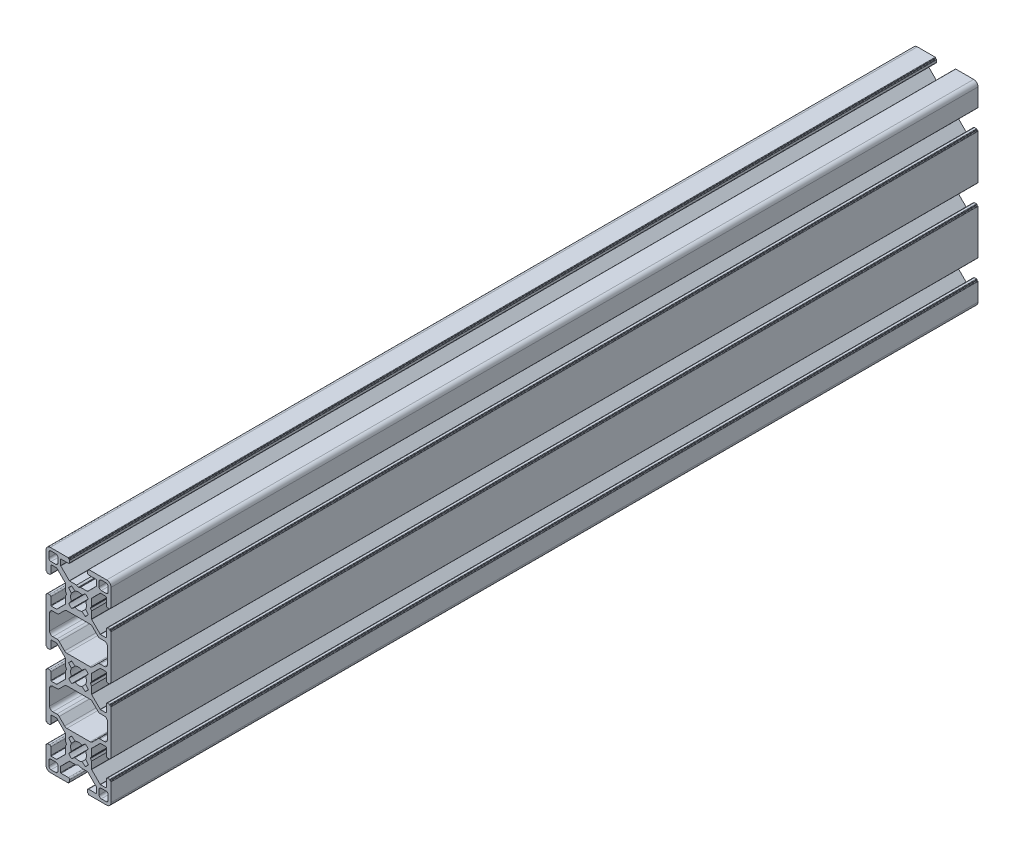
from build123d import *

# Parameters (mm, degrees)
EXTRUDE_1_DEPTH = 400


with BuildPart() as part:
    # Эскиз1 → Бобышка-Вытянуть1 (new body)
    with BuildSketch(Plane.XY):
        with BuildLine():
            Line((6.004467258, 46.508963124), (5.542586948, 45.708962771))
            ThreePointArc((5.542586948, 45.708962771), (5.501165701, 45.608963035), (5.542586948, 45.508963298))
            Line((5.542586948, 45.508963298), (6.004467258, 44.708962945))
            Line((6.004467258, 44.708962945), (6.004467258, 41.487339598))
            ThreePointArc((6.004467258, 41.487339598), (6.019691347, 41.410802923), (6.063045884, 41.345918259))
            Line((6.063045884, 41.345918259), (9.991421447, 37.417541696))
            ThreePointArc((9.991421447, 37.417541696), (10.056306123, 37.374187133), (10.132842821, 37.358963035))
            Line((10.132842821, 37.358963035), (12.600000821, 37.358963035))
            ThreePointArc((12.600000821, 37.358963035), (12.741422177, 37.417541678), (12.800000821, 37.558963035))
            Line((12.800000821, 37.558963035), (12.800000821, 40.958963035))
            ThreePointArc((12.800000821, 40.958963035), (12.975736752, 41.383227103), (13.400000821, 41.558963035))
            Line((13.400000821, 41.558963035), (14.300000334, 41.558963035))
            ThreePointArc((14.300000334, 41.558963035), (14.44142169, 41.500384391), (14.500000334, 41.358963035))
            Line((14.500000334, 41.358963035), (14.500000334, 41.258963035))
            ThreePointArc((14.500000334, 41.258963035), (14.558578978, 41.117541678), (14.700000334, 41.058963035))
            Line((14.700000334, 41.058963035), (14.8, 41.058963035))
            ThreePointArc((14.8, 41.058963035), (14.941421356, 41.000384391), (15, 40.858963035))
            Line((15, 40.858963035), (15, 20.358963035))
            ThreePointArc((15, 20.358963035), (14.941421356, 20.217541678), (14.8, 20.158963035))
            Line((14.8, 20.158963035), (14.700000334, 20.158963035))
            ThreePointArc((14.700000334, 20.158963035), (14.558578978, 20.100384391), (14.500000334, 19.958963035))
            Line((14.500000334, 19.958963035), (14.500000334, 19.858963035))
            ThreePointArc((14.500000334, 19.858963035), (14.44142169, 19.717541678), (14.300000334, 19.658963035))
            Line((14.300000334, 19.658963035), (13.400000821, 19.658963035))
            ThreePointArc((13.400000821, 19.658963035), (12.975736752, 19.834698966), (12.800000821, 20.258963035))
            Line((12.800000821, 20.258963035), (12.800000821, 23.658963035))
            ThreePointArc((12.800000821, 23.658963035), (12.741422177, 23.800384391), (12.600000821, 23.858963035))
            Line((12.600000821, 23.858963035), (10.132842821, 23.858963035))
            ThreePointArc((10.132842821, 23.858963035), (10.056306123, 23.843738936), (9.991421447, 23.800384373))
            Line((9.991421447, 23.800384373), (6.063045884, 19.87200781))
            ThreePointArc((6.063045884, 19.87200781), (6.019691347, 19.807123146), (6.004467258, 19.730586472))
            Line((6.004467258, 19.730586472), (6.004467258, 16.508963124))
            Line((6.004467258, 16.508963124), (5.542586948, 15.708962771))
            ThreePointArc((5.542586948, 15.708962771), (5.515792105, 15.608963035), (5.542586948, 15.508963298))
            Line((5.542586948, 15.508963298), (6.004467258, 14.708962945))
            Line((6.004467258, 14.708962945), (6.004467258, 11.487339598))
            ThreePointArc((6.004467258, 11.487339598), (6.019691347, 11.410802923), (6.063045884, 11.345918259))
            Line((6.063045884, 11.345918259), (9.991421447, 7.417541696))
            ThreePointArc((9.991421447, 7.417541696), (10.056306123, 7.374187133), (10.132842821, 7.358963035))
            Line((10.132842821, 7.358963035), (12.600000821, 7.358963035))
            ThreePointArc((12.600000821, 7.358963035), (12.741422177, 7.417541678), (12.800000821, 7.558963035))
            Line((12.800000821, 7.558963035), (12.800000821, 10.958963035))
            ThreePointArc((12.800000821, 10.958963035), (12.975736752, 11.383227103), (13.400000821, 11.558963035))
            Line((13.400000821, 11.558963035), (14.300000334, 11.558963035))
            ThreePointArc((14.300000334, 11.558963035), (14.44142169, 11.500384391), (14.500000334, 11.358963035))
            Line((14.500000334, 11.358963035), (14.500000334, 11.258962909))
            ThreePointArc((14.500000334, 11.258962909), (14.558578978, 11.117541553), (14.700000334, 11.058962909))
            Line((14.700000334, 11.058962909), (14.8, 11.058962909))
            ThreePointArc((14.8, 11.058962909), (14.941421356, 11.000384266), (15, 10.858962909))
            Line((15, 10.858962909), (15, 2.608963035))
            ThreePointArc((15, 2.608963035), (14.414213562, 1.194749472), (13, 0.608963035))
            Line((13, 0.608963035), (4.75, 0.608963035))
            ThreePointArc((4.75, 0.608963035), (4.608578644, 0.667541678), (4.55, 0.808963035))
            Line((4.55, 0.808963035), (4.55, 0.908963035))
            ThreePointArc((4.55, 0.908963035), (4.491421356, 1.050384391), (4.35, 1.108963035))
            Line((4.35, 1.108963035), (4.25, 1.108963035))
            ThreePointArc((4.25, 1.108963035), (4.108578644, 1.167541678), (4.05, 1.308963035))
            Line((4.05, 1.308963035), (4.05, 2.208963035))
            ThreePointArc((4.05, 2.208963035), (4.225735931, 2.633227103), (4.65, 2.808963035))
            Line((4.65, 2.808963035), (8.05, 2.808963035))
            ThreePointArc((8.05, 2.808963035), (8.191421356, 2.867541678), (8.25, 3.008963035))
            Line((8.25, 3.008963035), (8.25, 5.476120035))
            ThreePointArc((8.25, 5.476120035), (8.234775894, 5.552656772), (8.191421308, 5.617541481))
            Line((8.191421308, 5.617541481), (4.258577305, 9.550384483))
            ThreePointArc((4.258577305, 9.550384483), (4.193692724, 9.593738965), (4.117156145, 9.608963035))
            Line((4.117156145, 9.608963035), (0.899999648, 9.608963035))
            Line((0.899999648, 9.608963035), (0.101934004, 10.069726315))
            ThreePointArc((0.101934004, 10.069726315), (0, 10.097039442), (-0.101934004, 10.069726315))
            Line((-0.101934004, 10.069726315), (-0.899999648, 9.608963035))
            Line((-0.899999648, 9.608963035), (-4.117156145, 9.608963035))
            ThreePointArc((-4.117156145, 9.608963035), (-4.193692724, 9.593738965), (-4.258577305, 9.550384483))
            Line((-4.258577305, 9.550384483), (-8.191421308, 5.617541481))
            ThreePointArc((-8.191421308, 5.617541481), (-8.234775894, 5.552656772), (-8.25, 5.476120035))
            Line((-8.25, 5.476120035), (-8.25, 3.008963035))
            ThreePointArc((-8.25, 3.008963035), (-8.191421356, 2.867541678), (-8.05, 2.808963035))
            Line((-8.05, 2.808963035), (-4.65, 2.808963035))
            ThreePointArc((-4.65, 2.808963035), (-4.225735931, 2.633227103), (-4.05, 2.208963035))
            Line((-4.05, 2.208963035), (-4.05, 1.308963035))
            ThreePointArc((-4.05, 1.308963035), (-4.108578644, 1.167541678), (-4.25, 1.108963035))
            Line((-4.25, 1.108963035), (-4.35, 1.108963035))
            ThreePointArc((-4.35, 1.108963035), (-4.491421356, 1.050384391), (-4.55, 0.908963035))
            Line((-4.55, 0.908963035), (-4.55, 0.808963035))
            ThreePointArc((-4.55, 0.808963035), (-4.608578644, 0.667541678), (-4.75, 0.608963035))
            Line((-4.75, 0.608963035), (-13, 0.608963035))
            ThreePointArc((-13, 0.608963035), (-14.414213562, 1.194749472), (-15, 2.608963035))
            Line((-15, 2.608963035), (-15, 10.858962909))
            ThreePointArc((-15, 10.858962909), (-14.941421356, 11.000384266), (-14.8, 11.058962909))
            Line((-14.8, 11.058962909), (-14.700000334, 11.058962909))
            ThreePointArc((-14.700000334, 11.058962909), (-14.558578978, 11.117541553), (-14.500000334, 11.258962909))
            Line((-14.500000334, 11.258962909), (-14.500000334, 11.358963035))
            ThreePointArc((-14.500000334, 11.358963035), (-14.44142169, 11.500384391), (-14.300000334, 11.558963035))
            Line((-14.300000334, 11.558963035), (-13.400000821, 11.558963035))
            ThreePointArc((-13.400000821, 11.558963035), (-12.975736752, 11.383227103), (-12.800000821, 10.958963035))
            Line((-12.800000821, 10.958963035), (-12.800000821, 7.558963035))
            ThreePointArc((-12.800000821, 7.558963035), (-12.741422177, 7.417541678), (-12.600000821, 7.358963035))
            Line((-12.600000821, 7.358963035), (-10.132842821, 7.358963035))
            ThreePointArc((-10.132842821, 7.358963035), (-10.056306123, 7.374187133), (-9.991421447, 7.417541696))
            Line((-9.991421447, 7.417541696), (-6.063045884, 11.345918259))
            ThreePointArc((-6.063045884, 11.345918259), (-6.019691347, 11.410802923), (-6.004467258, 11.487339598))
            Line((-6.004467258, 11.487339598), (-6.004467258, 14.708962945))
            Line((-6.004467258, 14.708962945), (-5.542586948, 15.508963298))
            ThreePointArc((-5.542586948, 15.508963298), (-5.515792105, 15.608963035), (-5.542586948, 15.708962771))
            Line((-5.542586948, 15.708962771), (-6.004467258, 16.508963124))
            Line((-6.004467258, 16.508963124), (-6.004467258, 19.730586472))
            ThreePointArc((-6.004467258, 19.730586472), (-6.019691347, 19.807123146), (-6.063045884, 19.87200781))
            Line((-6.063045884, 19.87200781), (-9.991421447, 23.800384373))
            ThreePointArc((-9.991421447, 23.800384373), (-10.056306123, 23.843738936), (-10.132842821, 23.858963035))
            Line((-10.132842821, 23.858963035), (-12.600000821, 23.858963035))
            ThreePointArc((-12.600000821, 23.858963035), (-12.741422177, 23.800384391), (-12.800000821, 23.658963035))
            Line((-12.800000821, 23.658963035), (-12.800000821, 20.258963035))
            ThreePointArc((-12.800000821, 20.258963035), (-12.975736752, 19.834698966), (-13.400000821, 19.658963035))
            Line((-13.400000821, 19.658963035), (-14.300000334, 19.658963035))
            ThreePointArc((-14.300000334, 19.658963035), (-14.44142169, 19.717541678), (-14.500000334, 19.858963035))
            Line((-14.500000334, 19.858963035), (-14.500000334, 19.958963035))
            ThreePointArc((-14.500000334, 19.958963035), (-14.558578978, 20.100384391), (-14.700000334, 20.158963035))
            Line((-14.700000334, 20.158963035), (-14.8, 20.158963035))
            ThreePointArc((-14.8, 20.158963035), (-14.941421356, 20.217541678), (-15, 20.358963035))
            Line((-15, 20.358963035), (-15, 40.858963035))
            ThreePointArc((-15, 40.858963035), (-14.941421356, 41.000384391), (-14.8, 41.058963035))
            Line((-14.8, 41.058963035), (-14.700000334, 41.058963035))
            ThreePointArc((-14.700000334, 41.058963035), (-14.558578978, 41.117541678), (-14.500000334, 41.258963035))
            Line((-14.500000334, 41.258963035), (-14.500000334, 41.358963035))
            ThreePointArc((-14.500000334, 41.358963035), (-14.44142169, 41.500384391), (-14.300000334, 41.558963035))
            Line((-14.300000334, 41.558963035), (-13.400000821, 41.558963035))
            ThreePointArc((-13.400000821, 41.558963035), (-12.975736752, 41.383227103), (-12.800000821, 40.958963035))
            Line((-12.800000821, 40.958963035), (-12.800000821, 37.558963035))
            ThreePointArc((-12.800000821, 37.558963035), (-12.741422177, 37.417541678), (-12.600000821, 37.358963035))
            Line((-12.600000821, 37.358963035), (-10.132842821, 37.358963035))
            ThreePointArc((-10.132842821, 37.358963035), (-10.056306123, 37.374187133), (-9.991421447, 37.417541696))
            Line((-9.991421447, 37.417541696), (-6.063045884, 41.345918259))
            ThreePointArc((-6.063045884, 41.345918259), (-6.019691347, 41.410802923), (-6.004467258, 41.487339598))
            Line((-6.004467258, 41.487339598), (-6.004467258, 44.708962945))
            Line((-6.004467258, 44.708962945), (-5.542586948, 45.508963298))
            ThreePointArc((-5.542586948, 45.508963298), (-5.501165701, 45.608963035), (-5.542586948, 45.708962771))
            Line((-5.542586948, 45.708962771), (-6.004467258, 46.508963124))
            Line((-6.004467258, 46.508963124), (-6.004467258, 49.730586472))
            ThreePointArc((-6.004467258, 49.730586472), (-6.004467253, 49.813429171), (-6.063045884, 49.87200781))
            Line((-6.063045884, 49.87200781), (-9.991421447, 53.800384373))
            ThreePointArc((-9.991421447, 53.800384373), (-10.056306123, 53.843738936), (-10.132842821, 53.858963035))
            Line((-10.132842821, 53.858963035), (-12.600000821, 53.858963035))
            ThreePointArc((-12.600000821, 53.858963035), (-12.741422177, 53.800384391), (-12.800000821, 53.658963035))
            Line((-12.800000821, 53.658963035), (-12.800000821, 50.258963035))
            ThreePointArc((-12.800000821, 50.258963035), (-12.975736752, 49.834698966), (-13.400000821, 49.658963035))
            Line((-13.400000821, 49.658963035), (-14.300000334, 49.658963035))
            ThreePointArc((-14.300000334, 49.658963035), (-14.44142169, 49.717541678), (-14.500000334, 49.858963035))
            Line((-14.500000334, 49.858963035), (-14.500000334, 49.958963035))
            ThreePointArc((-14.500000334, 49.958963035), (-14.558578978, 50.100384391), (-14.700000334, 50.158963035))
            Line((-14.700000334, 50.158963035), (-14.8, 50.158963035))
            ThreePointArc((-14.8, 50.158963035), (-14.941421356, 50.217541678), (-15, 50.358963035))
            Line((-15, 50.358963035), (-15, 70.858963035))
            ThreePointArc((-15, 70.858963035), (-14.941421356, 71.000384391), (-14.8, 71.058963035))
            Line((-14.8, 71.058963035), (-14.700000334, 71.058963035))
            ThreePointArc((-14.700000334, 71.058963035), (-14.558578978, 71.117541678), (-14.500000334, 71.258963035))
            Line((-14.500000334, 71.258963035), (-14.500000334, 71.358963035))
            ThreePointArc((-14.500000334, 71.358963035), (-14.44142169, 71.500384391), (-14.300000334, 71.558963035))
            Line((-14.300000334, 71.558963035), (-13.400000821, 71.558963035))
            ThreePointArc((-13.400000821, 71.558963035), (-12.975736752, 71.383227103), (-12.800000821, 70.958963035))
            Line((-12.800000821, 70.958963035), (-12.800000821, 67.558963035))
            ThreePointArc((-12.800000821, 67.558963035), (-12.741422177, 67.417541678), (-12.600000821, 67.358963035))
            Line((-12.600000821, 67.358963035), (-10.132842821, 67.358963035))
            ThreePointArc((-10.132842821, 67.358963035), (-10.056306123, 67.374187133), (-9.991421447, 67.417541696))
            Line((-9.991421447, 67.417541696), (-6.063045884, 71.345918259))
            ThreePointArc((-6.063045884, 71.345918259), (-6.019691347, 71.410802923), (-6.004467258, 71.487339598))
            Line((-6.004467258, 71.487339598), (-6.004467258, 74.708962945))
            Line((-6.004467258, 74.708962945), (-5.542586948, 75.508963298))
            ThreePointArc((-5.542586948, 75.508963298), (-5.515792105, 75.608963035), (-5.542586948, 75.708962771))
            Line((-5.542586948, 75.708962771), (-6.004467258, 76.508963124))
            Line((-6.004467258, 76.508963124), (-6.004467258, 79.730586472))
            ThreePointArc((-6.004467258, 79.730586472), (-6.019691347, 79.807123146), (-6.063045884, 79.87200781))
            Line((-6.063045884, 79.87200781), (-9.991421447, 83.800384373))
            ThreePointArc((-9.991421447, 83.800384373), (-10.056306123, 83.843738936), (-10.132842821, 83.858963035))
            Line((-10.132842821, 83.858963035), (-12.600000821, 83.858963035))
            ThreePointArc((-12.600000821, 83.858963035), (-12.741422177, 83.800384391), (-12.800000821, 83.658963035))
            Line((-12.800000821, 83.658963035), (-12.800000821, 80.258963035))
            ThreePointArc((-12.800000821, 80.258963035), (-12.975736752, 79.834698966), (-13.400000821, 79.658963035))
            Line((-13.400000821, 79.658963035), (-14.300000334, 79.658963035))
            ThreePointArc((-14.300000334, 79.658963035), (-14.44142169, 79.717541678), (-14.500000334, 79.858963035))
            Line((-14.500000334, 79.858963035), (-14.500000334, 79.95896316))
            ThreePointArc((-14.500000334, 79.95896316), (-14.558578978, 80.100384516), (-14.700000334, 80.15896316))
            Line((-14.700000334, 80.15896316), (-14.8, 80.15896316))
            ThreePointArc((-14.8, 80.15896316), (-14.941421356, 80.217541804), (-15, 80.35896316))
            Line((-15, 80.35896316), (-15, 88.608963035))
            ThreePointArc((-15, 88.608963035), (-14.414213562, 90.023176597), (-13, 90.608963035))
            Line((-13, 90.608963035), (-4.75, 90.608963035))
            ThreePointArc((-4.75, 90.608963035), (-4.608578644, 90.550384391), (-4.55, 90.408963035))
            Line((-4.55, 90.408963035), (-4.55, 90.308963035))
            ThreePointArc((-4.55, 90.308963035), (-4.491421356, 90.167541678), (-4.35, 90.108963035))
            Line((-4.35, 90.108963035), (-4.25, 90.108963035))
            ThreePointArc((-4.25, 90.108963035), (-4.108578644, 90.050384391), (-4.05, 89.908963035))
            Line((-4.05, 89.908963035), (-4.05, 89.008963035))
            ThreePointArc((-4.05, 89.008963035), (-4.225735931, 88.584698966), (-4.65, 88.408963035))
            Line((-4.65, 88.408963035), (-8.05, 88.408963035))
            ThreePointArc((-8.05, 88.408963035), (-8.191421356, 88.350384391), (-8.25, 88.208963035))
            Line((-8.25, 88.208963035), (-8.25, 85.741806035))
            ThreePointArc((-8.25, 85.741806035), (-8.234775894, 85.665269298), (-8.191421308, 85.600384589))
            Line((-8.191421308, 85.600384589), (-4.258577305, 81.667541587))
            ThreePointArc((-4.258577305, 81.667541587), (-4.193692724, 81.624187104), (-4.117156145, 81.608963035))
            Line((-4.117156145, 81.608963035), (-0.899999648, 81.608963035))
            Line((-0.899999648, 81.608963035), (-0.101934004, 81.148199754))
            ThreePointArc((-0.101934004, 81.148199754), (0, 81.120886627), (0.101934004, 81.148199754))
            Line((0.101934004, 81.148199754), (0.899999648, 81.608963035))
            Line((0.899999648, 81.608963035), (4.117156145, 81.608963035))
            ThreePointArc((4.117156145, 81.608963035), (4.193692724, 81.624187104), (4.258577305, 81.667541587))
            Line((4.258577305, 81.667541587), (8.191421308, 85.600384589))
            ThreePointArc((8.191421308, 85.600384589), (8.234775894, 85.665269298), (8.25, 85.741806035))
            Line((8.25, 85.741806035), (8.25, 88.208963035))
            ThreePointArc((8.25, 88.208963035), (8.191421356, 88.350384391), (8.05, 88.408963035))
            Line((8.05, 88.408963035), (4.65, 88.408963035))
            ThreePointArc((4.65, 88.408963035), (4.225735931, 88.584698966), (4.05, 89.008963035))
            Line((4.05, 89.008963035), (4.05, 89.908963035))
            ThreePointArc((4.05, 89.908963035), (4.108578644, 90.050384391), (4.25, 90.108963035))
            Line((4.25, 90.108963035), (4.35, 90.108963035))
            ThreePointArc((4.35, 90.108963035), (4.491421356, 90.167541678), (4.55, 90.308963035))
            Line((4.55, 90.308963035), (4.55, 90.408963035))
            ThreePointArc((4.55, 90.408963035), (4.608578644, 90.550384391), (4.75, 90.608963035))
            Line((4.75, 90.608963035), (13, 90.608963035))
            ThreePointArc((13, 90.608963035), (14.414213562, 90.023176597), (15, 88.608963035))
            Line((15, 88.608963035), (15, 80.35896316))
            ThreePointArc((15, 80.35896316), (14.941421356, 80.217541804), (14.8, 80.15896316))
            Line((14.8, 80.15896316), (14.700000334, 80.15896316))
            ThreePointArc((14.700000334, 80.15896316), (14.558578978, 80.100384516), (14.500000334, 79.95896316))
            Line((14.500000334, 79.95896316), (14.500000334, 79.858963035))
            ThreePointArc((14.500000334, 79.858963035), (14.44142169, 79.717541678), (14.300000334, 79.658963035))
            Line((14.300000334, 79.658963035), (13.400000821, 79.658963035))
            ThreePointArc((13.400000821, 79.658963035), (12.975736752, 79.834698966), (12.800000821, 80.258963035))
            Line((12.800000821, 80.258963035), (12.800000821, 83.658963035))
            ThreePointArc((12.800000821, 83.658963035), (12.741422177, 83.800384391), (12.600000821, 83.858963035))
            Line((12.600000821, 83.858963035), (10.132842821, 83.858963035))
            ThreePointArc((10.132842821, 83.858963035), (10.056306123, 83.843738936), (9.991421447, 83.800384373))
            Line((9.991421447, 83.800384373), (6.063045884, 79.87200781))
            ThreePointArc((6.063045884, 79.87200781), (6.019691347, 79.807123146), (6.004467258, 79.730586472))
            Line((6.004467258, 79.730586472), (6.004467258, 76.508963124))
            Line((6.004467258, 76.508963124), (5.542586948, 75.708962771))
            ThreePointArc((5.542586948, 75.708962771), (5.515792105, 75.608963035), (5.542586948, 75.508963298))
            Line((5.542586948, 75.508963298), (6.004467258, 74.708962945))
            Line((6.004467258, 74.708962945), (6.004467258, 71.487339598))
            ThreePointArc((6.004467258, 71.487339598), (6.019691347, 71.410802923), (6.063045884, 71.345918259))
            Line((6.063045884, 71.345918259), (9.991421447, 67.417541696))
            ThreePointArc((9.991421447, 67.417541696), (10.056306123, 67.374187133), (10.132842821, 67.358963035))
            Line((10.132842821, 67.358963035), (12.600000821, 67.358963035))
            ThreePointArc((12.600000821, 67.358963035), (12.741422177, 67.417541678), (12.800000821, 67.558963035))
            Line((12.800000821, 67.558963035), (12.800000821, 70.958963035))
            ThreePointArc((12.800000821, 70.958963035), (12.975736752, 71.383227103), (13.400000821, 71.558963035))
            Line((13.400000821, 71.558963035), (14.300000334, 71.558963035))
            ThreePointArc((14.300000334, 71.558963035), (14.44142169, 71.500384391), (14.500000334, 71.358963035))
            Line((14.500000334, 71.358963035), (14.500000334, 71.258963035))
            ThreePointArc((14.500000334, 71.258963035), (14.558578978, 71.117541678), (14.700000334, 71.058963035))
            Line((14.700000334, 71.058963035), (14.8, 71.058963035))
            ThreePointArc((14.8, 71.058963035), (14.941421356, 71.000384391), (15, 70.858963035))
            Line((15, 70.858963035), (15, 50.358963035))
            ThreePointArc((15, 50.358963035), (14.941421356, 50.217541678), (14.8, 50.158963035))
            Line((14.8, 50.158963035), (14.700000334, 50.158963035))
            ThreePointArc((14.700000334, 50.158963035), (14.558578978, 50.100384391), (14.500000334, 49.958963035))
            Line((14.500000334, 49.958963035), (14.500000334, 49.858963035))
            ThreePointArc((14.500000334, 49.858963035), (14.44142169, 49.717541678), (14.300000334, 49.658963035))
            Line((14.300000334, 49.658963035), (13.400000821, 49.658963035))
            ThreePointArc((13.400000821, 49.658963035), (12.975736752, 49.834698966), (12.800000821, 50.258963035))
            Line((12.800000821, 50.258963035), (12.800000821, 53.658963035))
            ThreePointArc((12.800000821, 53.658963035), (12.741422177, 53.800384391), (12.600000821, 53.858963035))
            Line((12.600000821, 53.858963035), (10.132842821, 53.858963035))
            ThreePointArc((10.132842821, 53.858963035), (10.056306123, 53.843738936), (9.991421447, 53.800384373))
            Line((9.991421447, 53.800384373), (6.063045884, 49.87200781))
            ThreePointArc((6.063045884, 49.87200781), (6.019691347, 49.807123146), (6.004467258, 49.730586472))
            Line((6.004467258, 49.730586472), (6.004467258, 46.508963124))
        make_face()
        with BuildLine():
            Line((1.600130621, 12.328401803), (3.154670945, 11.103627173))
            ThreePointArc((3.154670945, 11.103627173), (3.897156783, 11.727962003), (4.518401855, 12.473034994))
            Line((4.518401855, 12.473034994), (3.28056155, 14.008833067))
            ThreePointArc((3.28056155, 14.008833067), (3.65, 15.608963035), (3.28056155, 17.209093003))
            Line((3.28056155, 17.209093003), (4.518401855, 18.744891075))
            ThreePointArc((4.518401855, 18.744891075), (3.897156783, 19.489964066), (3.154670945, 20.114298897))
            Line((3.154670945, 20.114298897), (1.600130621, 18.889524267))
            ThreePointArc((1.600130621, 18.889524267), (0, 19.258963035), (-1.600130621, 18.889524267))
            Line((-1.600130621, 18.889524267), (-3.154670945, 20.114298897))
            ThreePointArc((-3.154670945, 20.114298897), (-3.897156783, 19.489964066), (-4.518401855, 18.744891075))
            Line((-4.518401855, 18.744891075), (-3.28056155, 17.209093003))
            ThreePointArc((-3.28056155, 17.209093003), (-3.65, 15.608963035), (-3.28056155, 14.008833067))
            Line((-3.28056155, 14.008833067), (-4.518401855, 12.473034994))
            ThreePointArc((-4.518401855, 12.473034994), (-3.897156783, 11.727962003), (-3.154670945, 11.103627173))
            Line((-3.154670945, 11.103627173), (-1.600130621, 12.328401803))
            ThreePointArc((-1.600130621, 12.328401803), (0, 11.958963035), (1.600130621, 12.328401803))
        make_face(mode=Mode.SUBTRACT)
        with BuildLine():
            Line((10.500000904, 6.108962861), (12.700000904, 6.108962861))
            ThreePointArc((12.700000904, 6.108962861), (13.407107685, 5.816069642), (13.700000904, 5.108962861))
            Line((13.700000904, 5.108962861), (13.700000904, 2.908962861))
            ThreePointArc((13.700000904, 2.908962861), (13.407107685, 2.20185608), (12.700000904, 1.908962861))
            Line((12.700000904, 1.908962861), (10.500000904, 1.908962861))
            ThreePointArc((10.500000904, 1.908962861), (9.792894123, 2.20185608), (9.500000904, 2.908962861))
            Line((9.500000904, 2.908962861), (9.500000904, 5.108962861))
            ThreePointArc((9.500000904, 5.108962861), (9.792894123, 5.816069642), (10.500000904, 6.108962861))
        make_face(mode=Mode.SUBTRACT)
        with BuildLine():
            Line((8.927207818, 25.069623242), (6.410354062, 22.552769143))
            ThreePointArc((6.410354062, 22.552769143), (5.923719026, 22.227609968), (5.349693844, 22.113429242))
            Line((5.349693844, 22.113429242), (-5.349693844, 22.113429242))
            ThreePointArc((-5.349693844, 22.113429242), (-5.923719026, 22.227609968), (-6.410354062, 22.552769143))
            Line((-6.410354062, 22.552769143), (-8.927207746, 25.06962317))
            ThreePointArc((-8.927207746, 25.06962317), (-9.413842755, 25.394782323), (-9.987867904, 25.508963035))
            Line((-9.987867904, 25.508963035), (-11.849999904, 25.508963035))
            ThreePointArc((-11.849999904, 25.508963035), (-12.910660076, 25.948302863), (-13.349999904, 27.008963035))
            Line((-13.349999904, 27.008963035), (-13.349999904, 34.208963035))
            ThreePointArc((-13.349999904, 34.208963035), (-12.910660076, 35.269623206), (-11.849999904, 35.708963035))
            Line((-11.849999904, 35.708963035), (-9.987867904, 35.708963035))
            ThreePointArc((-9.987867904, 35.708963035), (-9.413842802, 35.823143727), (-8.927207818, 36.148302827))
            Line((-8.927207818, 36.148302827), (-6.410354008, 38.665156981))
            ThreePointArc((-6.410354008, 38.665156981), (-5.923718979, 38.990316121), (-5.349693818, 39.104496827))
            Line((-5.349693818, 39.104496827), (5.349693818, 39.104496827))
            ThreePointArc((5.349693818, 39.104496827), (5.923718979, 38.990316121), (6.410354008, 38.665156981))
            Line((6.410354008, 38.665156981), (8.927207818, 36.148302827))
            ThreePointArc((8.927207818, 36.148302827), (9.413842802, 35.823143727), (9.987867904, 35.708963035))
            Line((9.987867904, 35.708963035), (11.849999904, 35.708963035))
            ThreePointArc((11.849999904, 35.708963035), (12.910660076, 35.269623206), (13.349999904, 34.208963035))
            Line((13.349999904, 34.208963035), (13.349999904, 27.008963035))
            ThreePointArc((13.349999904, 27.008963035), (12.910660076, 25.948302863), (11.849999904, 25.508963035))
            Line((11.849999904, 25.508963035), (9.987867904, 25.508963035))
            ThreePointArc((9.987867904, 25.508963035), (9.413842802, 25.394782343), (8.927207818, 25.069623242))
        make_face(mode=Mode.SUBTRACT)
        with BuildLine():
            Line((-1.600130621, 42.328401803), (-3.154670945, 41.103627173))
            ThreePointArc((-3.154670945, 41.103627173), (-3.897156783, 41.727962003), (-4.518401855, 42.473034994))
            Line((-4.518401855, 42.473034994), (-3.28056155, 44.008833067))
            ThreePointArc((-3.28056155, 44.008833067), (-3.65, 45.608963035), (-3.28056155, 47.209093003))
            Line((-3.28056155, 47.209093003), (-4.518401855, 48.744891075))
            ThreePointArc((-4.518401855, 48.744891075), (-3.897156783, 49.489964066), (-3.154670945, 50.114298897))
            Line((-3.154670945, 50.114298897), (-1.600130621, 48.889524267))
            ThreePointArc((-1.600130621, 48.889524267), (0, 49.258963035), (1.600130621, 48.889524267))
            Line((1.600130621, 48.889524267), (3.154670945, 50.114298897))
            ThreePointArc((3.154670945, 50.114298897), (3.897156783, 49.489964066), (4.518401855, 48.744891075))
            Line((4.518401855, 48.744891075), (3.28056155, 47.209093003))
            ThreePointArc((3.28056155, 47.209093003), (3.65, 45.608963035), (3.28056155, 44.008833067))
            Line((3.28056155, 44.008833067), (4.518401855, 42.473034994))
            ThreePointArc((4.518401855, 42.473034994), (3.897156783, 41.727962003), (3.154670945, 41.103627173))
            Line((3.154670945, 41.103627173), (1.600130621, 42.328401803))
            ThreePointArc((1.600130621, 42.328401803), (0, 41.958963035), (-1.600130621, 42.328401803))
        make_face(mode=Mode.SUBTRACT)
        with BuildLine():
            Line((-9.500000904, 2.908962861), (-9.500000904, 5.108962861))
            ThreePointArc((-9.500000904, 5.108962861), (-9.792894123, 5.816069642), (-10.500000904, 6.108962861))
            Line((-10.500000904, 6.108962861), (-12.700000904, 6.108962861))
            ThreePointArc((-12.700000904, 6.108962861), (-13.407107685, 5.816069642), (-13.700000904, 5.108962861))
            Line((-13.700000904, 5.108962861), (-13.700000904, 2.908962861))
            ThreePointArc((-13.700000904, 2.908962861), (-13.407107685, 2.20185608), (-12.700000904, 1.908962861))
            Line((-12.700000904, 1.908962861), (-10.500000904, 1.908962861))
            ThreePointArc((-10.500000904, 1.908962861), (-9.792894123, 2.20185608), (-9.500000904, 2.908962861))
        make_face(mode=Mode.SUBTRACT)
        with BuildLine():
            Line((-5.349693818, 52.113429242), (5.349693818, 52.113429242))
            ThreePointArc((5.349693818, 52.113429242), (5.923718979, 52.227609948), (6.410354008, 52.552769089))
            Line((6.410354008, 52.552769089), (8.927207818, 55.069623242))
            ThreePointArc((8.927207818, 55.069623242), (9.413842802, 55.394782343), (9.987867904, 55.508963035))
            Line((9.987867904, 55.508963035), (11.849999904, 55.508963035))
            ThreePointArc((11.849999904, 55.508963035), (12.910660076, 55.948302863), (13.349999904, 57.008963035))
            Line((13.349999904, 57.008963035), (13.349999904, 64.208963035))
            ThreePointArc((13.349999904, 64.208963035), (12.910660076, 65.269623206), (11.849999904, 65.708963035))
            Line((11.849999904, 65.708963035), (9.987867904, 65.708963035))
            ThreePointArc((9.987867904, 65.708963035), (9.413842802, 65.823143727), (8.927207818, 66.148302827))
            Line((8.927207818, 66.148302827), (6.410354062, 68.665156927))
            ThreePointArc((6.410354062, 68.665156927), (5.923719026, 68.990316102), (5.349693844, 69.104496827))
            Line((5.349693844, 69.104496827), (-5.349693844, 69.104496827))
            ThreePointArc((-5.349693844, 69.104496827), (-5.923719026, 68.990316102), (-6.410354062, 68.665156927))
            Line((-6.410354062, 68.665156927), (-8.927207746, 66.1483029))
            ThreePointArc((-8.927207746, 66.1483029), (-9.413842755, 65.823143746), (-9.987867904, 65.708963035))
            Line((-9.987867904, 65.708963035), (-11.849999904, 65.708963035))
            ThreePointArc((-11.849999904, 65.708963035), (-12.910660076, 65.269623206), (-13.349999904, 64.208963035))
            Line((-13.349999904, 64.208963035), (-13.349999904, 57.008963035))
            ThreePointArc((-13.349999904, 57.008963035), (-12.910660076, 55.948302863), (-11.849999904, 55.508963035))
            Line((-11.849999904, 55.508963035), (-9.987867904, 55.508963035))
            ThreePointArc((-9.987867904, 55.508963035), (-9.413842802, 55.394782343), (-8.927207818, 55.069623242))
            Line((-8.927207818, 55.069623242), (-6.410354008, 52.552769089))
            ThreePointArc((-6.410354008, 52.552769089), (-5.923718979, 52.227609948), (-5.349693818, 52.113429242))
        make_face(mode=Mode.SUBTRACT)
        with BuildLine():
            Line((-1.600130621, 78.889524267), (-3.154670945, 80.114298897))
            ThreePointArc((-3.154670945, 80.114298897), (-3.897156783, 79.489964066), (-4.518401855, 78.744891075))
            Line((-4.518401855, 78.744891075), (-3.28056155, 77.209093003))
            ThreePointArc((-3.28056155, 77.209093003), (-3.65, 75.608963035), (-3.28056155, 74.008833067))
            Line((-3.28056155, 74.008833067), (-4.518401855, 72.473034994))
            ThreePointArc((-4.518401855, 72.473034994), (-3.897156783, 71.727962003), (-3.154670945, 71.103627173))
            Line((-3.154670945, 71.103627173), (-1.600130621, 72.328401803))
            ThreePointArc((-1.600130621, 72.328401803), (0, 71.958963035), (1.600130621, 72.328401803))
            Line((1.600130621, 72.328401803), (3.154670945, 71.103627173))
            ThreePointArc((3.154670945, 71.103627173), (3.897156783, 71.727962003), (4.518401855, 72.473034994))
            Line((4.518401855, 72.473034994), (3.28056155, 74.008833067))
            ThreePointArc((3.28056155, 74.008833067), (3.65, 75.608963035), (3.28056155, 77.209093003))
            Line((3.28056155, 77.209093003), (4.518401855, 78.744891075))
            ThreePointArc((4.518401855, 78.744891075), (3.897156783, 79.489964066), (3.154670945, 80.114298897))
            Line((3.154670945, 80.114298897), (1.600130621, 78.889524267))
            ThreePointArc((1.600130621, 78.889524267), (0, 79.258963035), (-1.600130621, 78.889524267))
        make_face(mode=Mode.SUBTRACT)
        with BuildLine():
            Line((-10.500000904, 85.108963209), (-12.700000904, 85.108963209))
            ThreePointArc((-12.700000904, 85.108963209), (-13.407107685, 85.401856427), (-13.700000904, 86.108963209))
            Line((-13.700000904, 86.108963209), (-13.700000904, 88.308963209))
            ThreePointArc((-13.700000904, 88.308963209), (-13.407107685, 89.01606999), (-12.700000904, 89.308963209))
            Line((-12.700000904, 89.308963209), (-10.500000904, 89.308963209))
            ThreePointArc((-10.500000904, 89.308963209), (-9.792894123, 89.01606999), (-9.500000904, 88.308963209))
            Line((-9.500000904, 88.308963209), (-9.500000904, 86.108963209))
            ThreePointArc((-9.500000904, 86.108963209), (-9.792894123, 85.401856427), (-10.500000904, 85.108963209))
        make_face(mode=Mode.SUBTRACT)
        with BuildLine():
            Line((9.500000904, 88.308963209), (9.500000904, 86.108963209))
            ThreePointArc((9.500000904, 86.108963209), (9.792894123, 85.401856427), (10.500000904, 85.108963209))
            Line((10.500000904, 85.108963209), (12.700000904, 85.108963209))
            ThreePointArc((12.700000904, 85.108963209), (13.407107685, 85.401856427), (13.700000904, 86.108963209))
            Line((13.700000904, 86.108963209), (13.700000904, 88.308963209))
            ThreePointArc((13.700000904, 88.308963209), (13.407107685, 89.01606999), (12.700000904, 89.308963209))
            Line((12.700000904, 89.308963209), (10.500000904, 89.308963209))
            ThreePointArc((10.500000904, 89.308963209), (9.792894123, 89.01606999), (9.500000904, 88.308963209))
        make_face(mode=Mode.SUBTRACT)
    extrude(amount=EXTRUDE_1_DEPTH)


solid = part.part
